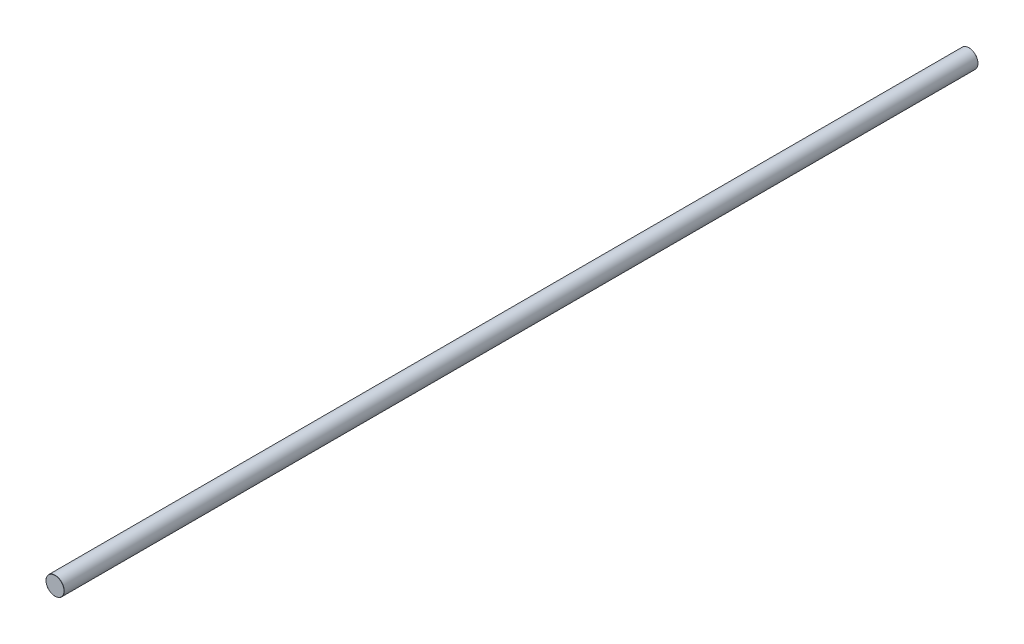
from build123d import *

# Parameters (mm, degrees)
SKETCH1_R           = 5
BOSS_EXTRUDE1_DEPTH = 500
FILLET1_R           = 0.1


with BuildPart() as part:
    # Sketch1 → Boss-Extrude1 (new body)
    with BuildSketch(Plane.XY):
        Circle(SKETCH1_R)
    extrude(amount=BOSS_EXTRUDE1_DEPTH)

    # Fillet1
    fillet1_edges = [part.edges().sort_by_distance(p)[0] for p in [
        (-5, 0, 0),
        (-5, 0, 500),
    ]]
    fillet(fillet1_edges, radius=FILLET1_R)


solid = part.part
